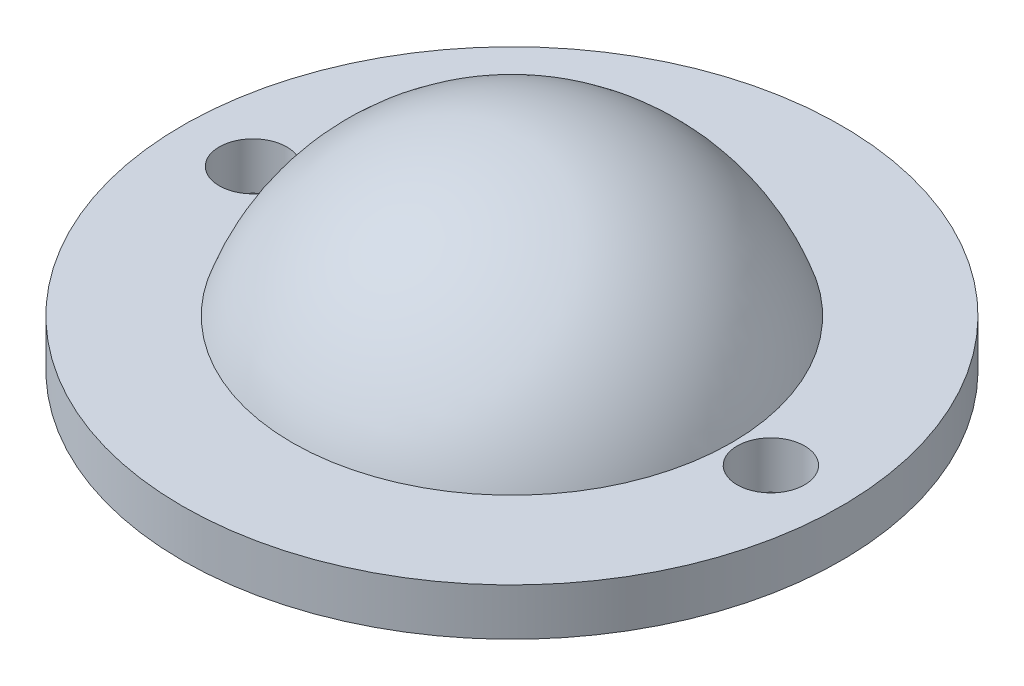
from build123d import *

# Parameters (mm, degrees)
SKETCH6_R          = 2.15
CUT_EXTRUDE1_DEPTH = 11


with BuildPart() as part:
    # Sketch3 → Revolve1 (revolve)
    with BuildSketch(Plane(origin=(0, 0, 0), x_dir=(0, 0, -1), z_dir=(1, 0, 0))):
        with BuildLine():
            Line((21, 0), (21, 3))
            Line((21, 3), (14, 3))
            ThreePointArc((14, 3), (8.602325267, 10.243255374), (0, 13))
            Line((0, 13), (0, -2))
            ThreePointArc((0, -2), (5.590169944, -1.495934691), (11, 0))
            Line((11, 0), (21, 0))
        make_face()
    revolve(axis=Axis((0, 13, 0), (0, -1, 0)))

    # Sketch6 → Cut-Extrude1 (cut, through all)
    with BuildSketch(Plane(origin=(0, 3, 0), x_dir=(1, 0, 0), z_dir=(0, 1, 0))):
        with Locations((16.5, 0)):
            Circle(SKETCH6_R)
        with Locations((-16.5, 0)):
            Circle(SKETCH6_R)
    extrude(amount=-CUT_EXTRUDE1_DEPTH, mode=Mode.SUBTRACT)


with BuildPart() as body_2:
    # Sketch4 → Revolve3 (revolve)
    with BuildSketch(Plane(origin=(0, 0, 0), x_dir=(0, 0, -1), z_dir=(1, 0, 0))):
        with BuildLine():
            Line((0, -7), (0, 8))
            ThreePointArc((0, 8), (7.5, 0.5), (0, -7))
        make_face()
    revolve(axis=Axis((0, 0, 0), (0, -1, 0)))


solid = Compound([part.part, body_2.part])
